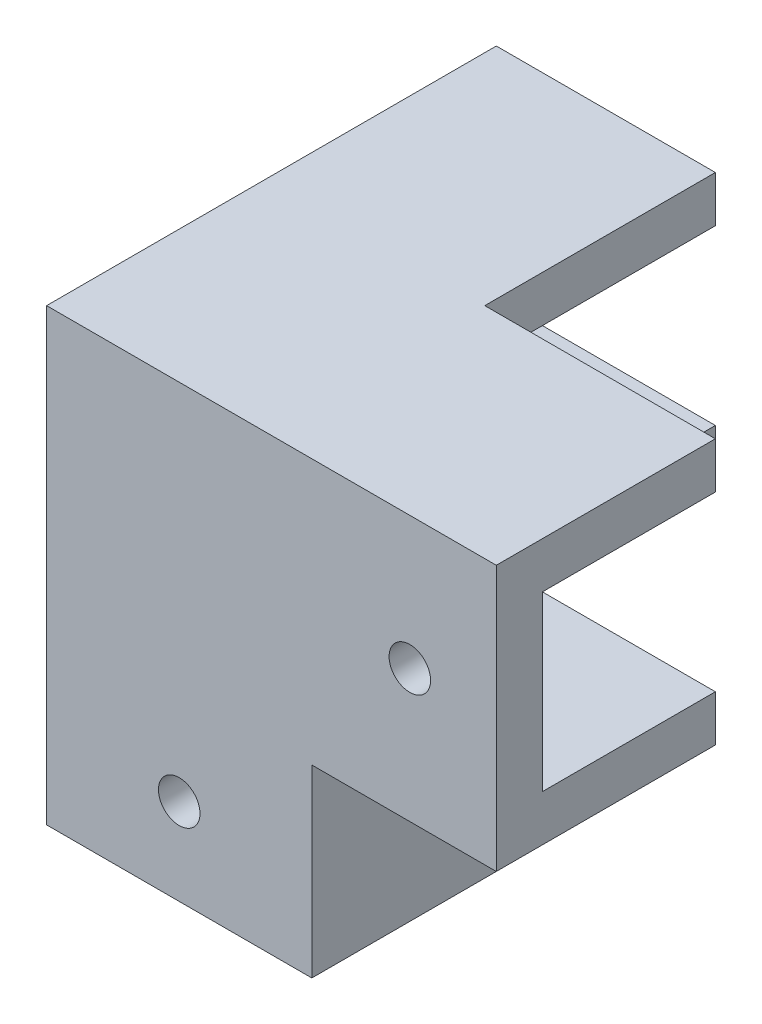
from build123d import *

# Parameters (mm, degrees)
EXTRUDE_1_DEPTH      = 20
SKETCH_2_W           = 18.9
SKETCH_2_H           = 20
EXTRUDE_2_DEPTH      = 4
SKETCH_3_W           = 15
SKETCH_3_H           = 4
EXTRUDE_3_DEPTH      = 39
SKETCH_4_W           = 19
SKETCH_4_H           = 4
EXTRUDE_4_DEPTH      = 16
SKETCH_5_W           = 4
SKETCH_5_H           = 15
EXTRUDE_5_DEPTH      = 20
EXTRUDE_5_DEPTH_BACK = 15
SKETCH_6_W           = 19
SKETCH_6_H           = 4
EXTRUDE_6_DEPTH      = 16
SKETCH_7_R           = 1.8
CUT_EXTRUDE_1_DEPTH  = 16
SKETCH_8_R           = 1.8
CUT_EXTRUDE_2_DEPTH  = 16
SKETCH_9_R           = 1.8
CUT_EXTRUDE_3_DEPTH  = 16


with BuildPart() as part:
    # 草图1 → 凸台-拉伸1 (new body)
    with BuildSketch(Plane(origin=(0, 0, 0), x_dir=(1, 0, 0), z_dir=(0, 1, 0))):
        Polygon((8.973333333, -3.090335191), (8.973333333, 0.909664809), (-6.026666667, 0.909664809), (-6.026666667, 15.909664809), (8.973333333, 15.909664809), (8.973333333, 19.909664809), (-4.573333333, 19.909664809), (-10.026666667, 19.909664809), (-10.026666667, 0.495974831), (-10.026666667, -3.090335191), align=None)
    extrude(amount=EXTRUDE_1_DEPTH)



with BuildPart() as body_2:
    # 草图2 → 凸台-拉伸2 (new body)
    with BuildSketch(Plane(origin=(8.973333333, 0, 0), x_dir=(0, 0, -1), z_dir=(1, 0, 0))):
        with Locations((6.359664809, 10)):
            Rectangle(SKETCH_2_W, SKETCH_2_H)
    extrude(amount=EXTRUDE_2_DEPTH)


with BuildPart() as part_1:
    add(part.part)

    add(body_2.part)  # 凸台-拉伸3 merges body 2
    # 草图3 → 凸台-拉伸3 (add)
    with BuildSketch(Plane.ZY.offset(10.026666667)):
        with Locations((-8.409664809, 37)):
            Rectangle(SKETCH_3_W, SKETCH_3_H)
        Polygon((-0.909664809, 20), (3.090335191, 20), (3.090335191, 39), (-0.909664809, 39), (-0.909664809, 35), align=None)
    extrude(amount=-EXTRUDE_3_DEPTH)

    # 草图4 → 凸台-拉伸4 (add)
    with BuildSketch(Plane(origin=(12.973333333, 0, 0), x_dir=(0, 0, -1), z_dir=(1, 0, 0))):
        with Locations((6.409664809, 18)):
            Rectangle(SKETCH_4_W, SKETCH_4_H)
    extrude(amount=EXTRUDE_4_DEPTH)

    # 草图5 → 凸台-拉伸5 (add, two sides)
    with BuildSketch(Plane(origin=(0, 0, -15.909664809), x_dir=(-1, 0, 0), z_dir=(0, 0, -1))) as extrude_5_sk:
        Polygon((6.026666667, 35), (10.026666667, 35), (10.026666667, 39), (-8.973333333, 39), (-8.973333333, 35), align=None)
        with Locations((8.026666667, 27.5)):
            Rectangle(SKETCH_5_W, SKETCH_5_H)
    extrude(amount=EXTRUDE_5_DEPTH)
    extrude(extrude_5_sk.sketch, amount=-EXTRUDE_5_DEPTH_BACK)

    # 草图6 → 凸台-拉伸6 (add)
    with BuildSketch(Plane(origin=(0, 0, -19.909664809), x_dir=(-1, 0, 0), z_dir=(0, 0, -1))):
        with Locations((0.526666667, 18)):
            Rectangle(SKETCH_6_W, SKETCH_6_H)
    extrude(amount=EXTRUDE_6_DEPTH)

    # 草图7 → 切除-拉伸1 (cut)
    with BuildSketch(Plane.XY.offset(3.090335191)):
        with Locations((21.473333333, 27.5)):
            Circle(SKETCH_7_R)
    extrude(amount=-CUT_EXTRUDE_1_DEPTH, mode=Mode.SUBTRACT)

    # 草图8 → 切除-拉伸2 (cut)
    with BuildSketch(Plane.ZY.offset(10.026666667)):
        with Locations((-28.409664809, 27.5)):
            Circle(SKETCH_8_R)
        with Locations((-8.409664809, 7.5)):
            Circle(SKETCH_8_R)
    extrude(amount=-CUT_EXTRUDE_2_DEPTH, mode=Mode.SUBTRACT)

    # 草图9 → 切除-拉伸3 (cut)
    with BuildSketch(Plane.XY.offset(3.090335191)):
        with Locations((1.473333333, 7.5)):
            Circle(SKETCH_9_R)
    extrude(amount=-CUT_EXTRUDE_3_DEPTH, mode=Mode.SUBTRACT)


solid = part_1.part
